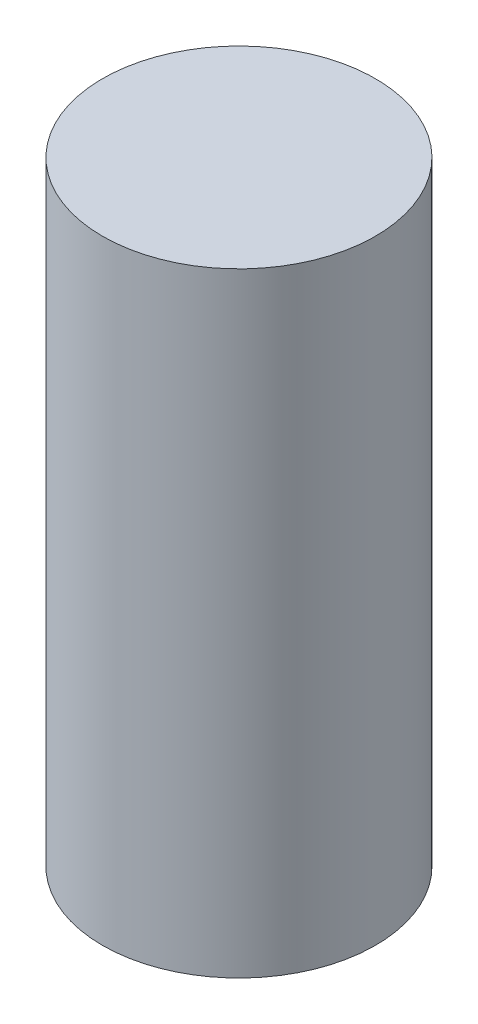
from build123d import *

# Parameters (mm, degrees)
SKETCH1_R           = 10
BOSS_EXTRUDE1_DEPTH = 45


with BuildPart() as part:
    # Sketch1 → Boss-Extrude1 (new body)
    with BuildSketch(Plane(origin=(0, 0, 0), x_dir=(1, 0, 0), z_dir=(0, 1, 0))):
        Circle(SKETCH1_R)
    extrude(amount=BOSS_EXTRUDE1_DEPTH)


solid = part.part
